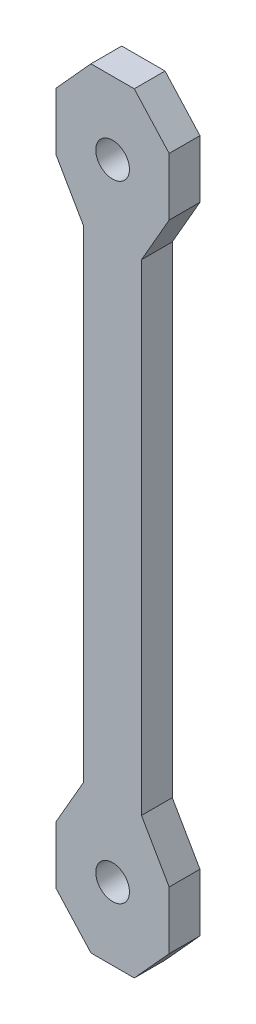
from build123d import *

# Parameters (mm, degrees)
CROQUIS1_R              = 3.5
SALIENTE_EXTRUIR1_DEPTH = 6.4


with BuildPart() as part:
    # Croquis1 → Saliente-Extruir1 (new body)
    with BuildSketch(Plane.XY):
        Polygon((-6, 15.149188933), (-6, -34.850811067), (-11.75, -44.850811067), (-11.75, -56.850811067), (-4.5, -64.850811067), (4.5, -64.850811067), (11.75, -56.850811067), (11.75, -44.850811067), (6, -34.850811067), (6, 15.149188933), (6, 65.149188933), (11.75, 75.149188933), (11.75, 87.149188933), (4.5, 95.149188933), (-4.5, 95.149188933), (-11.75, 87.149188933), (-11.75, 75.149188933), (-6, 65.149188933), align=None)
        with Locations((0, -49.850811067)):
            Circle(CROQUIS1_R, mode=Mode.SUBTRACT)
        with Locations((0, 80.149188933)):
            Circle(CROQUIS1_R, mode=Mode.SUBTRACT)
    extrude(amount=SALIENTE_EXTRUIR1_DEPTH)


solid = part.part
